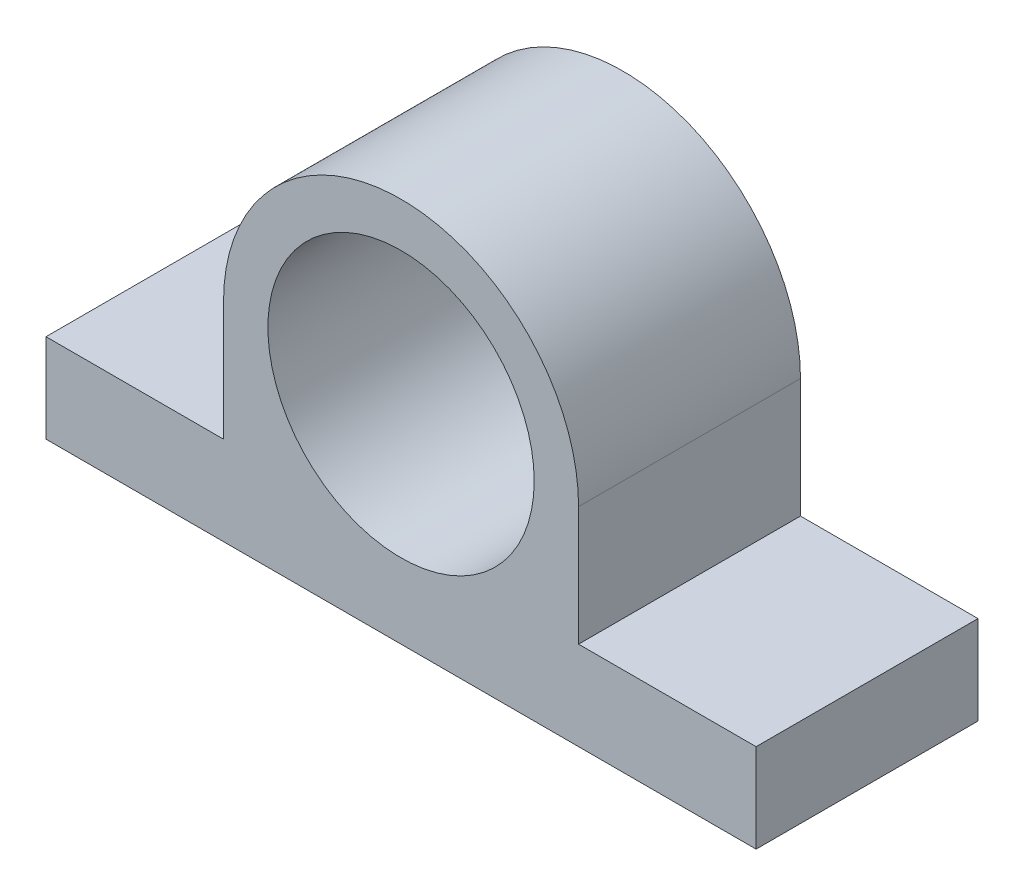
from build123d import *

# Parameters (mm, degrees)
SKETCH1_R           = 15
BOSS_EXTRUDE1_DEPTH = 25


with BuildPart() as part:
    # Sketch1 → Boss-Extrude1 (new body)
    with BuildSketch(Plane.XY):
        with BuildLine():
            Line((40, 0), (-40, 0))
            Line((-40, 0), (-40, 10))
            Line((-40, 10), (-20, 10))
            Line((-20, 10), (-20, 23.41991342))
            ThreePointArc((-20, 23.41991342), (0, 43.41991342), (20, 23.41991342))
            Line((20, 23.41991342), (20, 10))
            Line((20, 10), (40, 10))
            Line((40, 10), (40, 0))
        make_face()
        with Locations((0, 23.41991342)):
            Circle(SKETCH1_R, mode=Mode.SUBTRACT)
    extrude(amount=BOSS_EXTRUDE1_DEPTH)


solid = part.part
